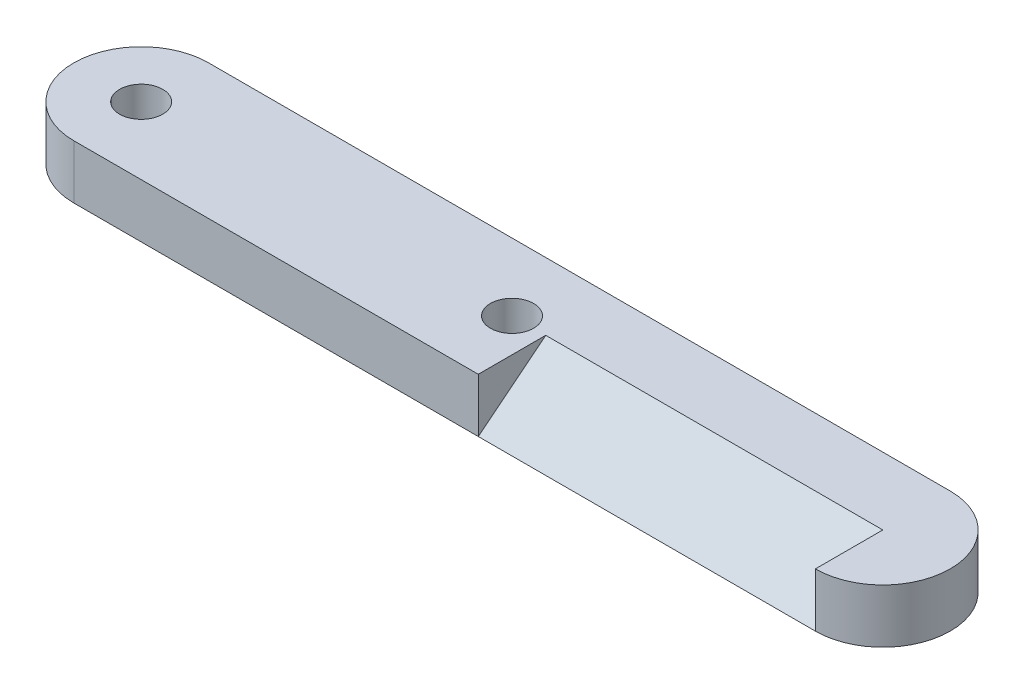
from build123d import *

# Parameters (mm, degrees)
BOSS_EXTRUDE1_DEPTH = 4
SKETCH2_R           = 1.6
CUT_EXTRUDE1_DEPTH  = 5
SKETCH5_W           = 25
SKETCH5_H           = 4
CUT_EXTRUDE2_DEPTH  = 5
BOSS_EXTRUDE3_DEPTH = 25


with BuildPart() as part:
    # Sketch1 → Boss-Extrude1 (new body)
    with BuildSketch(Plane(origin=(0, 0, 0), x_dir=(1, 0, 0), z_dir=(0, 1, 0))):
        with BuildLine():
            Line((0, 5), (55, 5))
            ThreePointArc((55, 5), (60, 0), (55, -5))
            Line((55, -5), (0, -5))
            ThreePointArc((0, -5), (-5, 0), (0, 5))
        make_face()
    extrude(amount=BOSS_EXTRUDE1_DEPTH)

    # Sketch2 → Cut-Extrude1 (cut, through all)
    with BuildSketch(Plane(origin=(0, 4, 0), x_dir=(1, 0, 0), z_dir=(0, 1, 0))):
        Circle(SKETCH2_R)
        with Locations((27.5, 0)):
            Circle(SKETCH2_R)
    extrude(amount=-CUT_EXTRUDE1_DEPTH, mode=Mode.SUBTRACT)

    # Sketch5 → Cut-Extrude2 (cut)
    with BuildSketch(Plane.XY.offset(5)):
        with Locations((42.5, 2)):
            Rectangle(SKETCH5_W, SKETCH5_H)
    extrude(amount=-CUT_EXTRUDE2_DEPTH, mode=Mode.SUBTRACT)

    # Sketch6 → Boss-Extrude3 (add)
    with BuildSketch(Plane(origin=(30, 0, 0), x_dir=(0, 0, -1), z_dir=(1, 0, 0))):
        Polygon((0, 4), (-5, 0), (0, 0), align=None)
    extrude(amount=BOSS_EXTRUDE3_DEPTH)


solid = part.part
